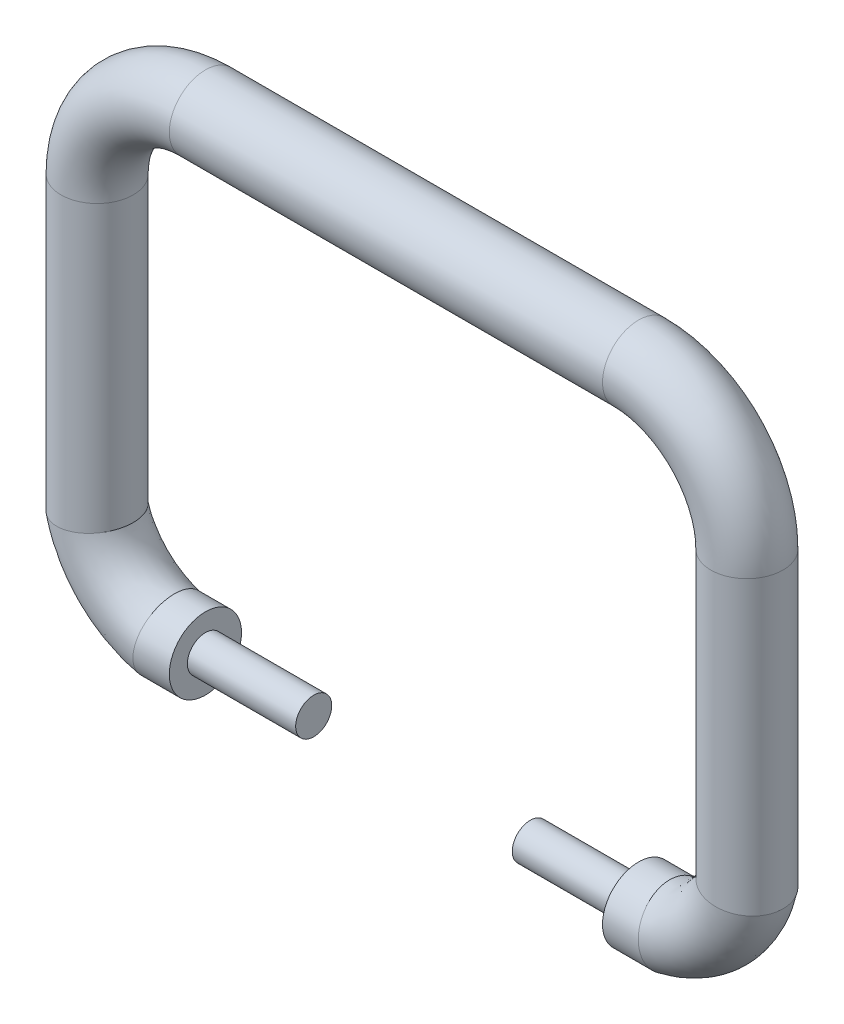
from build123d import *

# Parameters (mm, degrees)
SKETCH2_R          = 5
SKETCH6_R          = 7.5
SKETCH6_R_2        = 2.5
CUT_EXTRUDE1_DEPTH = 15
SKETCH7_R          = 7.5
SKETCH7_R_2        = 2.5
CUT_EXTRUDE2_DEPTH = 15


with BuildPart() as part:
    # Sweep1: sweep along a path in Sketch1
    with BuildLine(Plane.XY) as sweep1_path:
        Line((0, 0), (-30, 0))
        ThreePointArc((-30, 0), (-40.606601718, -4.393398282), (-45, -15))
        Line((-45, -15), (-45, -55))
        ThreePointArc((-45, -55), (-41.369540362, -61.369540362), (-35, -65))
        Line((-35, -65), (-15, -65))
    # Sketch2 → Sweep1 (sweep)
    with BuildSketch(Plane(origin=(0, 0, 0), x_dir=(0, 0, -1), z_dir=(1, 0, 0))):
        Circle(SKETCH2_R)
    sweep1 = sweep(path=sweep1_path.line, transition=Transition.RIGHT)

    # Mirror3: Sweep1 across plane
    add(sweep1.mirror(Plane(origin=(0, 0, 0), x_dir=(0, 0, 1), z_dir=(1, 0, 0))))

    # Sketch6 → Cut-Extrude1 (cut)
    with BuildSketch(Plane(origin=(-15, 0, 0), x_dir=(0, 0, -1), z_dir=(1, 0, 0))):
        with Locations((0, -65)):
            Circle(SKETCH6_R)
        with Locations((0, -65)):
            Circle(SKETCH6_R_2, mode=Mode.SUBTRACT)
    extrude(amount=-CUT_EXTRUDE1_DEPTH, mode=Mode.SUBTRACT)

    # Sketch7 → Cut-Extrude2 (cut)
    with BuildSketch(Plane.ZY.offset(-15)):
        with Locations((0, -65)):
            Circle(SKETCH7_R)
        with Locations((0, -65)):
            Circle(SKETCH7_R_2, mode=Mode.SUBTRACT)
    extrude(amount=-CUT_EXTRUDE2_DEPTH, mode=Mode.SUBTRACT)


solid = part.part
